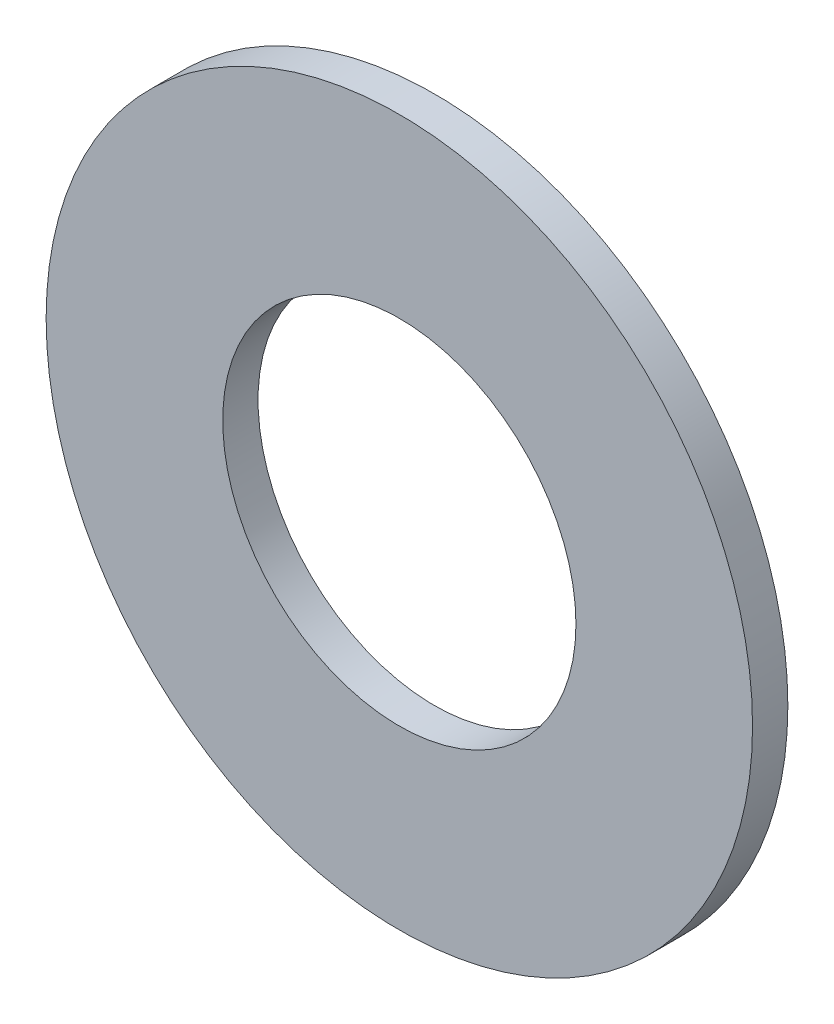
from build123d import *

# Parameters (mm, degrees)
SKETCH1_R           = 10
SKETCH1_R_2         = 5
BOSS_EXTRUDE1_DEPTH = 1


with BuildPart() as part:
    # Sketch1 → Boss-Extrude1 (new body)
    with BuildSketch(Plane.XY):
        Circle(SKETCH1_R)
        Circle(SKETCH1_R_2, mode=Mode.SUBTRACT)
    extrude(amount=BOSS_EXTRUDE1_DEPTH)


solid = part.part
